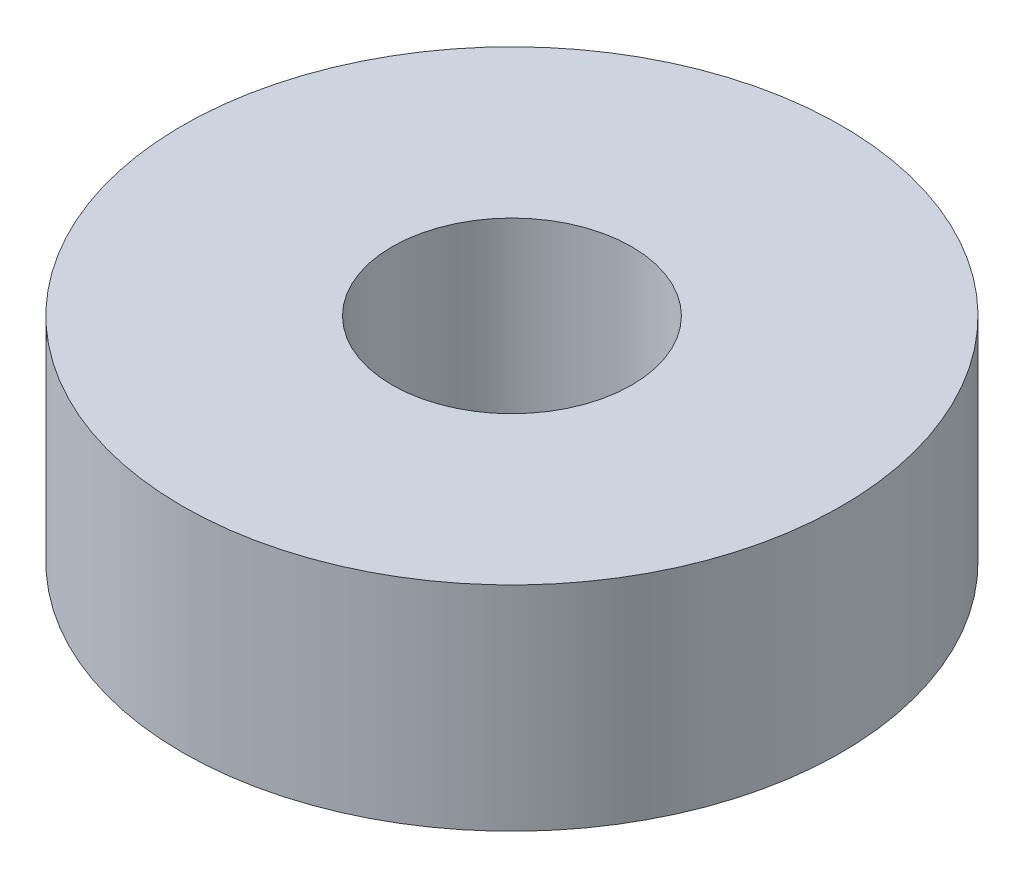
from build123d import *

# Parameters (mm, degrees)
SKETCH1_R           = 11
SKETCH1_R_2         = 4
BOSS_EXTRUDE1_DEPTH = 7.12


with BuildPart() as part:
    # Sketch1 → Boss-Extrude1 (new body)
    with BuildSketch(Plane(origin=(0, 0, 0), x_dir=(1, 0, 0), z_dir=(0, 1, 0))):
        Circle(SKETCH1_R)
        Circle(SKETCH1_R_2, mode=Mode.SUBTRACT)
    extrude(amount=BOSS_EXTRUDE1_DEPTH)


solid = part.part
